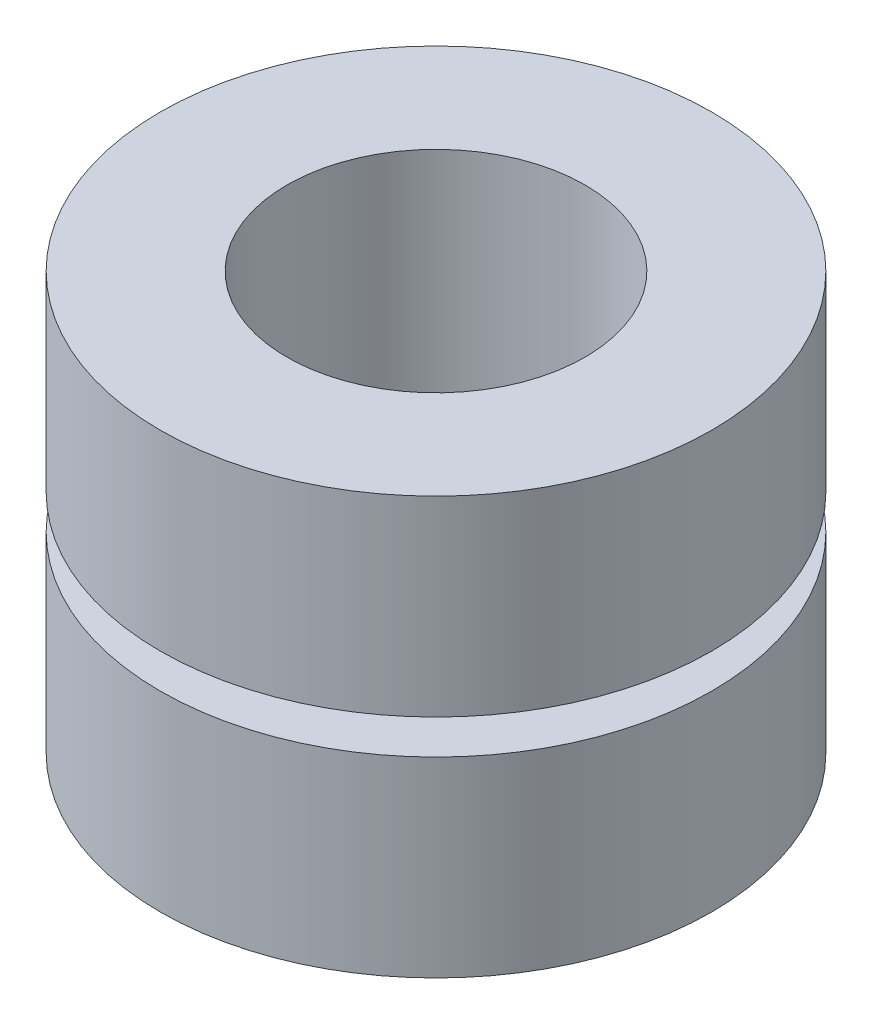
from build123d import *


with BuildPart() as part:
    # Sketch1 → Revolve1 (revolve)
    with BuildSketch(Plane.XY):
        Polygon((2.5146, 0), (2.5146, 7.0358), (4.6482, 7.0358), (4.6482, 3.81), (4.575879576, 3.81), (2.8194, 3.81), (2.8194, 3.2258), (4.6482, 3.2258), (4.6482, 0), align=None)
    revolve(axis=Axis((0, 0, 0), (0, 1, 0)))


solid = part.part
